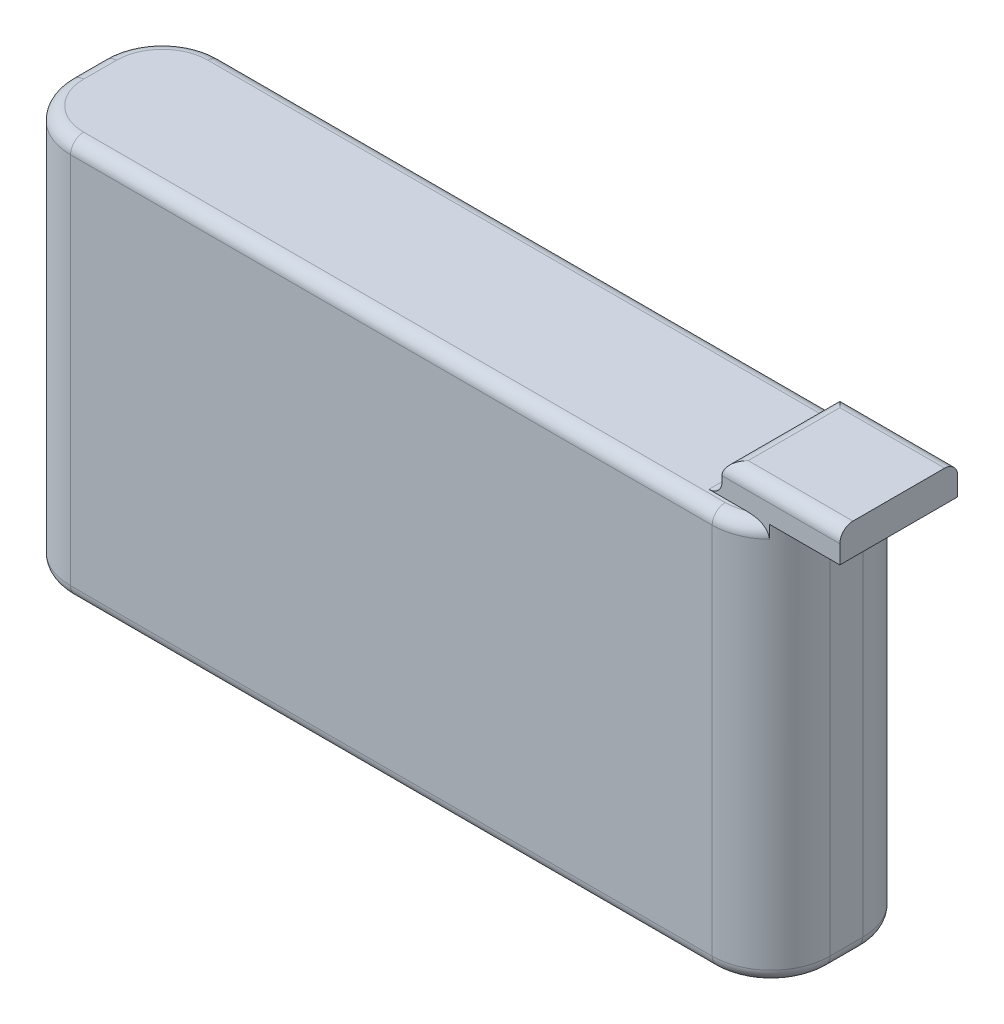
from build123d import *

# Parameters (mm, degrees)
SKETCH1_W           = 58
SKETCH1_H           = 30.5
BOSS_EXTRUDE1_DEPTH = 11.5
FILLET1_R           = 4.5
SKETCH2_W           = 9
SKETCH2_H           = 9
BOSS_EXTRUDE2_DEPTH = 2.4
FILLET2_R           = 1


with BuildPart() as part:
    # Sketch1 → Boss-Extrude1 (new body)
    with BuildSketch(Plane.XY):
        with Locations((29, 15.25)):
            Rectangle(SKETCH1_W, SKETCH1_H)
    extrude(amount=BOSS_EXTRUDE1_DEPTH)

    # Fillet1
    fillet1_edges = [part.edges().sort_by_distance(p)[0] for p in [
        (58, 15.25, 11.5),
        (0, 15.25, 11.5),
        (58, 15.25, 0),
        (0, 15.25, 0),
    ]]
    fillet(fillet1_edges, radius=FILLET1_R)

    # Sketch2 → Boss-Extrude2 (add)
    with BuildSketch(Plane(origin=(0, 30.5, 0), x_dir=(1, 0, 0), z_dir=(0, 1, 0))):
        with Locations((57.5, -5.75)):
            Rectangle(SKETCH2_W, SKETCH2_H)
    extrude(amount=BOSS_EXTRUDE2_DEPTH)

    # Fillet2
    fillet2_edges = [part.edges().sort_by_distance(p)[0] for p in [
        (0, 0, 5.75),
        (0, 30.5, 5.75),
        (29, 0, 0),
        (58, 0, 5.75),
        (29, 0, 11.5),
        (56.681980515, 0, 10.181980515),
        (56.681980515, 0, 1.318019485),
        (1.318019485, 0, 10.181980515),
        (1.318019485, 0, 1.318019485),
        (29, 30.5, 0),
        (29, 30.5, 11.5),
        (55.177050983, 30.5, 11.175823272),
        (1.318019485, 30.5, 10.181980515),
        (1.318019485, 30.5, 1.318019485),
        (55.177050983, 30.5, 0.324176728),
        (53, 30.5, 5.75),
        (53, 32.9, 5.75),
        (57.5, 32.9, 10.25),
        (57.5, 32.9, 1.25),
    ]]
    fillet(fillet2_edges, radius=FILLET2_R)


solid = part.part
